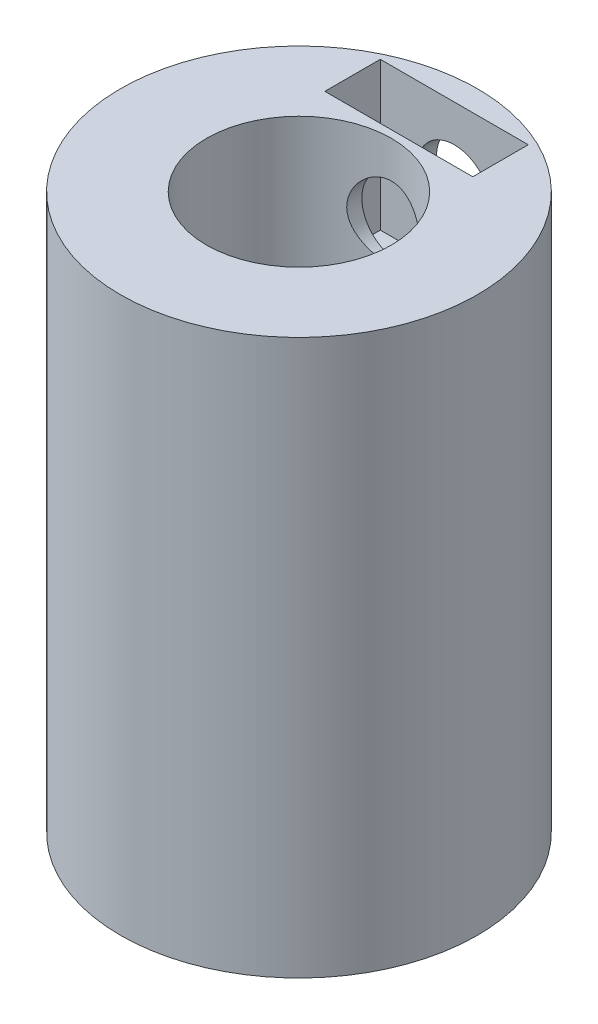
from build123d import *

# Parameters (mm, degrees)
IZIM1_R               = 4.825
BOSS_EXTRUDE1_DEPTH   = 15
IZIM1_6_R             = 2.5
CUT_EXTRUDE1_DEPTH    = 3
SKETCH2_R             = 2.5
CUT_EXTRUDE2_DEPTH    = 5
SKETCH3_R             = 1
CUT_EXTRUDE3_DEPTH    = 5.825
IZIM2_W               = 4
IZIM2_H               = 1.5
KES_EKSTR_ZYON1_DEPTH = 4


with BuildPart() as part:
    # Çizim1 → Boss-Extrude1 (new body)
    with BuildSketch(Plane(origin=(0, 0, 0), x_dir=(1, 0, 0), z_dir=(0, 1, 0))):
        Circle(IZIM1_R)
    extrude(amount=BOSS_EXTRUDE1_DEPTH)

    # Çizim1<6> → Cut-Extrude1 (cut)
    with BuildSketch(Plane(origin=(0, 0, 0), x_dir=(1, 0, 0), z_dir=(0, 1, 0))):
        Circle(IZIM1_6_R)
    extrude(amount=CUT_EXTRUDE1_DEPTH, mode=Mode.SUBTRACT)

    # Sketch2 → Cut-Extrude2 (cut)
    with BuildSketch(Plane(origin=(0, 15, 0), x_dir=(1, 0, 0), z_dir=(0, 1, 0))):
        Circle(SKETCH2_R)
    extrude(amount=-CUT_EXTRUDE2_DEPTH, mode=Mode.SUBTRACT)

    # Sketch3 → Cut-Extrude3 (cut, through all)
    with BuildSketch(Plane.XY):
        with Locations((0, 13)):
            Circle(SKETCH3_R)
    extrude(amount=-CUT_EXTRUDE3_DEPTH, mode=Mode.SUBTRACT)

    # Çizim2 → Kes-Ekstrüzyon1 (cut)
    with BuildSketch(Plane(origin=(0, 15, 0), x_dir=(1, 0, 0), z_dir=(0, 1, 0))):
        with Locations((0, 3.45)):
            Rectangle(IZIM2_W, IZIM2_H)
    extrude(amount=-KES_EKSTR_ZYON1_DEPTH, mode=Mode.SUBTRACT)


solid = part.part
